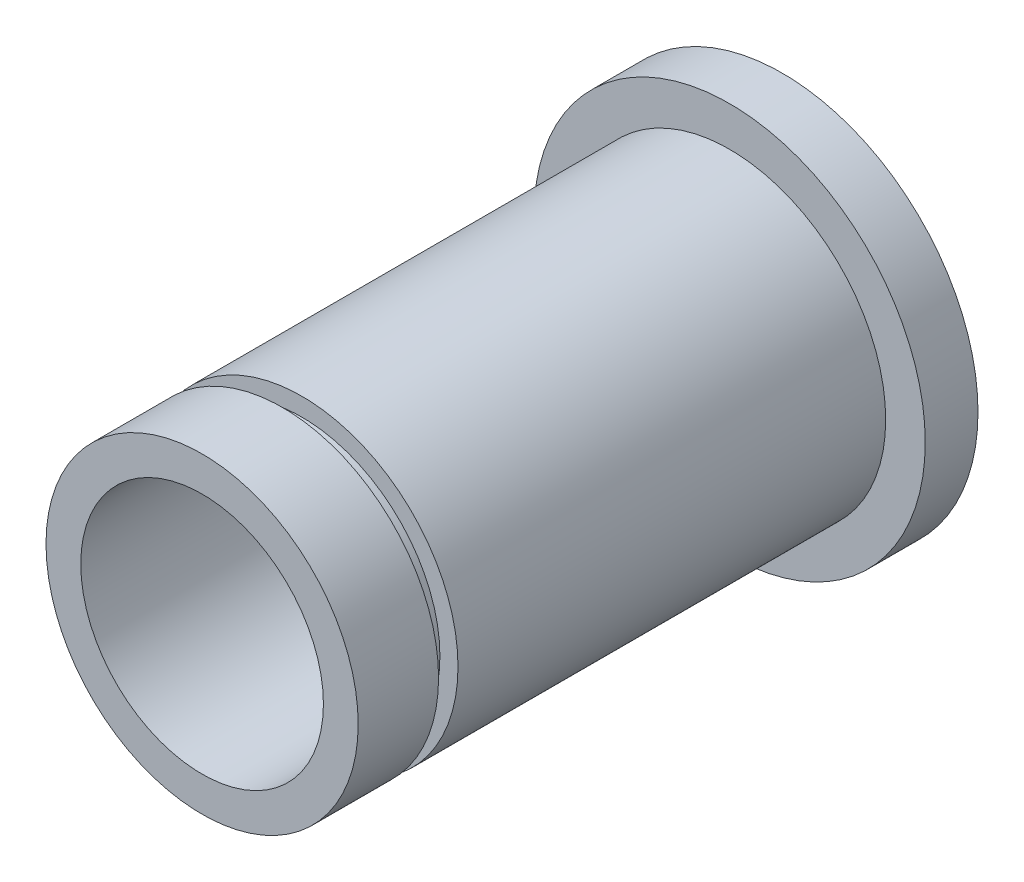
from build123d import *


with BuildPart() as part:
    # Sketch1 → Revolve1 (revolve)
    with BuildSketch(Plane(origin=(0, 0, 0), x_dir=(0, 0, -1), z_dir=(1, 0, 0)), mode=Mode.PRIVATE) as revolve1_sk:
        Polygon((0, 5.9182), (3.048, 5.9182), (3.048, 5.2324), (3.7846, 5.2324), (3.7846, 5.9182), (20, 5.9182), (20, 7.4182), (22, 7.4182), (22, 4.6), (0, 4.6), align=None)
    revolve(revolve1_sk.sketch.rotate(Axis((0, 0, 0), (0, 0, -1)), 90), axis=Axis((0, 0, 0), (0, 0, -1)))  # turned: the seam where the file's is


solid = part.part
